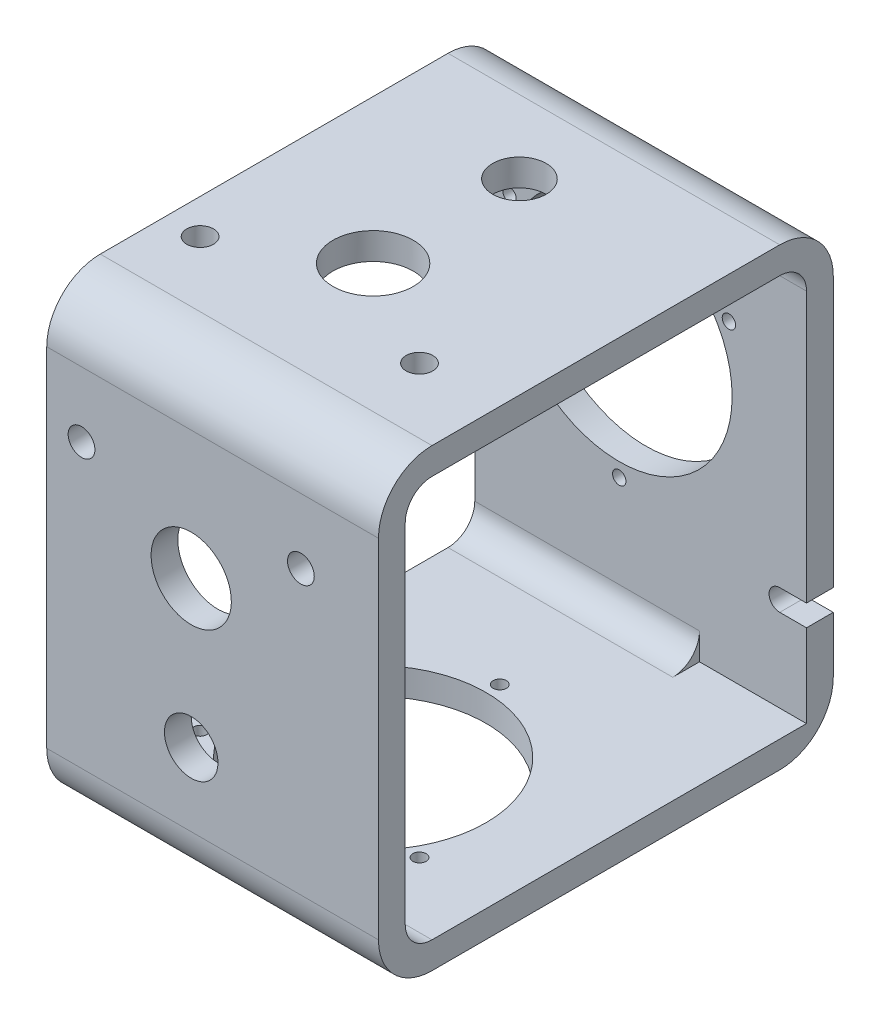
from build123d import *

# Parameters (mm, degrees)
SKETCH_2_W          = 85
SKETCH_2_H          = 85
SKETCH_2_W_2        = 75
SKETCH_2_H_2        = 75
EXTRUDE_1_DEPTH     = 70
SKETCH_3_R          = 21.1
CUT_EXTRUDE_1_DEPTH = 10
SKETCH_4_R          = 1.25
CUT_EXTRUDE_2_DEPTH = 10
FILLET_1_R          = 5
FILLET_2_R          = 10
SKETCH_5_W          = 97.414855886
SKETCH_5_H          = 125.778371442
CUT_EXTRUDE_3_DEPTH = 8
SKETCH_6_R          = 5
CUT_EXTRUDE_4_DEPTH = 10
SKETCH_13_R         = 7.5
SKETCH_13_R_2       = 2.5
CUT_EXTRUDE_7_DEPTH = 31
SKETCH_15_W         = 20
SKETCH_15_H         = 16
CUT_EXTRUDE_8_DEPTH = 12
CUT_EXTRUDE_9_DEPTH = 12


with BuildPart() as part:
    # 草图2 → 凸台-拉伸1 (new body)
    with BuildSketch(Plane(origin=(0, 0, 0), x_dir=(0, 0, -1), z_dir=(1, 0, 0))):
        Rectangle(SKETCH_2_W, SKETCH_2_H)
        Rectangle(SKETCH_2_W_2, SKETCH_2_H_2, mode=Mode.SUBTRACT)
    extrude(amount=EXTRUDE_1_DEPTH)

    # 草图3 → 切除-拉伸1 (cut)
    with BuildSketch(Plane.XY.offset(-37.5)):
        with Locations((35, 8.5)):
            Circle(SKETCH_3_R)
    cut_extrude_1 = extrude(amount=-CUT_EXTRUDE_1_DEPTH, mode=Mode.SUBTRACT)

    # 草图4 → 切除-拉伸2 (cut)
    with BuildSketch(Plane.XY.offset(-37.5)):
        with Locations((14.5, 20.335680518)):
            Circle(SKETCH_4_R)
        with Locations((35, -15.171361037)):
            Circle(SKETCH_4_R)
        with Locations((55.5, 20.335680518)):
            Circle(SKETCH_4_R)
    cut_extrude_2 = extrude(amount=-CUT_EXTRUDE_2_DEPTH, mode=Mode.SUBTRACT)

    # 镜向1: 切除-拉伸1, 切除-拉伸2 across plane
    add(cut_extrude_1.mirror(Plane(origin=(0, 0, 0), x_dir=(0, 0.7071067811865476, 0.7071067811865475), z_dir=(0, 0.7071067811865475, -0.7071067811865476))), mode=Mode.SUBTRACT)
    add(cut_extrude_2.mirror(Plane(origin=(0, 0, 0), x_dir=(0, 0.7071067811865476, 0.7071067811865475), z_dir=(0, 0.7071067811865475, -0.7071067811865476))), mode=Mode.SUBTRACT)

    # 圆角1
    fillet_1_edges = [part.edges().sort_by_distance(p)[0] for p in [
        (35, 37.5, 37.5),
        (35, -37.5, 37.5),
        (35, -37.5, -37.5),
        (35, 37.5, -37.5),
    ]]
    fillet(fillet_1_edges, radius=FILLET_1_R)

    # 圆角2
    fillet_2_edges = [part.edges().sort_by_distance(p)[0] for p in [
        (35, 42.5, 42.5),
        (35, -42.5, 42.5),
        (35, -42.5, -42.5),
        (35, 42.5, -42.5),
    ]]
    fillet(fillet_2_edges, radius=FILLET_2_R)

    # 草图5 → 切除-拉伸3 (cut)
    with BuildSketch(Plane.ZY):
        Rectangle(SKETCH_5_W, SKETCH_5_H)
    extrude(amount=-CUT_EXTRUDE_3_DEPTH, mode=Mode.SUBTRACT)

    # 草图6 → 切除-拉伸4 (cut)
    with BuildSketch(Plane(origin=(0, 42.5, 0), x_dir=(1, 0, 0), z_dir=(0, 1, 0))):
        with Locations((35, 18.85)):
            Circle(SKETCH_6_R)
    cut_extrude_4 = extrude(amount=-CUT_EXTRUDE_4_DEPTH, mode=Mode.SUBTRACT)

    # 镜向2: 切除-拉伸4 across plane
    add(cut_extrude_4.mirror(Plane(origin=(0, 0, 0), x_dir=(0, 0.7071067811865476, 0.7071067811865475), z_dir=(0, 0.7071067811865475, -0.7071067811865476))), mode=Mode.SUBTRACT)

    # 草图13 → 切除-拉伸7 (cut)
    with BuildSketch(Plane(origin=(0, 42.5, 0), x_dir=(1, 0, 0), z_dir=(0, 1, 0))):
        with Locations((35, -8.5)):
            Circle(SKETCH_13_R)
        with Locations((55.5, -20.335680518)):
            Circle(SKETCH_13_R_2)
        with Locations((14.5, -20.335680518)):
            Circle(SKETCH_13_R_2)
    cut_extrude_7 = extrude(amount=-CUT_EXTRUDE_7_DEPTH, mode=Mode.SUBTRACT)

    # 镜向5: 切除-拉伸7 across plane
    add(cut_extrude_7.mirror(Plane(origin=(0, 0, 0), x_dir=(0, 0.7071067811865476, 0.7071067811865475), z_dir=(0, 0.7071067811865475, -0.7071067811865476))), mode=Mode.SUBTRACT)

    # 草图15 → 切除-拉伸8 (cut)
    with BuildSketch(Plane.XY.offset(-37.5)):
        with Locations((60, -29.5)):
            Rectangle(SKETCH_15_W, SKETCH_15_H)
    extrude(amount=CUT_EXTRUDE_8_DEPTH, mode=Mode.SUBTRACT)

    # 草图16 → 切除-拉伸9 (cut)
    with BuildSketch(Plane.XY.offset(-37.5)):
        with BuildLine():
            Line((65, -17.990833729), (70, -17.990833729))
            ThreePointArc((70, -17.990833729), (72, -19.990833729), (70, -21.990833729))
            Line((70, -21.990833729), (65, -21.990833729))
            ThreePointArc((65, -21.990833729), (63, -19.990833729), (65, -17.990833729))
        make_face()
    extrude(amount=-CUT_EXTRUDE_9_DEPTH, mode=Mode.SUBTRACT)


solid = part.part
